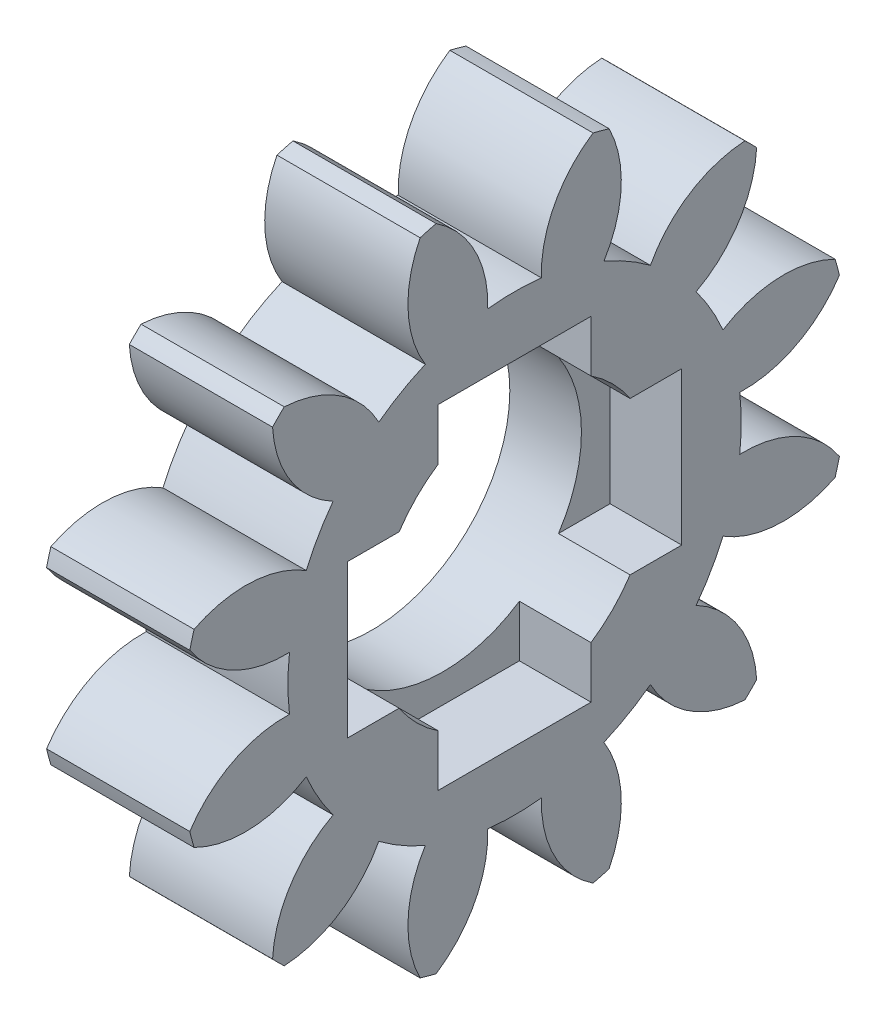
from build123d import *

# Parameters (mm, degrees)
BASPROSKE_W         = 3
BASPROSKE_H         = 7
TOOTHCUT_DEPTH      = 11.344080433
TEETHCUTS_COUNT     = 12
BORSKE_R            = 2.9
BORE_DEPTH          = 50.0000508
CUT_EXTRUDE_1_DEPTH = 1.5


with BuildPart() as part:
    # BasProSke → Base-Revolve (revolve)
    with BuildSketch(Plane(origin=(0, 0, 0), x_dir=(1, 0, 0), z_dir=(0, 1, 0)), mode=Mode.PRIVATE) as base_revolve_sk:
        with Locations((1.5, 3.5)):
            Rectangle(BASPROSKE_W, BASPROSKE_H)
    revolve(base_revolve_sk.sketch.rotate(Axis((-10, 0, 0), (1, 0, 0)), 180), axis=Axis((-10, 0, 0), (1, 0, 0)))

    # TooCutSke → ToothCut (cut, through all)
    with BuildSketch(Plane(origin=(0, 0, 0), x_dir=(0, 0, -1), z_dir=(1, 0, 0))):
        with BuildLine():
            ThreePointArc((0.562207301, 4.715604304), (0, 4.749), (-0.562207301, 4.715604304))
            ThreePointArc((-0.562207301, 4.715604304), (-0.837528627, 5.917009812), (-1.672850686, 6.823328788))
            ThreePointArc((-1.672850686, 6.823328788), (0, 7.0254), (1.672850686, 6.823328788))
            ThreePointArc((1.672850686, 6.823328788), (0.837528627, 5.917009812), (0.562207301, 4.715604304))
        make_face()
    toothcut = extrude(amount=TOOTHCUT_DEPTH, mode=Mode.SUBTRACT)

    # TeethCuts: ToothCut ×12 about axis
    teethcuts_axis = Axis((0, 0, 0), (1, 0, 0))
    for i in range(1, TEETHCUTS_COUNT):
        add(toothcut.rotate(teethcuts_axis, i * 360 / TEETHCUTS_COUNT), mode=Mode.SUBTRACT)

    # BorSke → Bore (cut, symmetric)
    with BuildSketch(Plane(origin=(0, 0, 0), x_dir=(0, 0, -1), z_dir=(1, 0, 0))):
        with Locations(Location((0, 0, 0), (0, 0, 180))):
            Circle(BORSKE_R)
    extrude(amount=BORE_DEPTH, both=True, mode=Mode.SUBTRACT)

    # 草图1 → 切除-拉伸1 (cut)
    with BuildSketch(Plane(origin=(3, 0, 0), x_dir=(0, 0, -1), z_dir=(1, 0, 0))):
        Polygon((-1.6, -1.6), (-1.6, -3.5), (1.6, -3.5), (1.6, -1.6), (3.5, -1.6), (3.5, 1.6), (1.6, 1.6), (1.6, 3.5), (-1.6, 3.5), (-1.6, 1.6), (-3.5, 1.6), (-3.5, -1.6), align=None)
    extrude(amount=-CUT_EXTRUDE_1_DEPTH, mode=Mode.SUBTRACT)


solid = part.part
